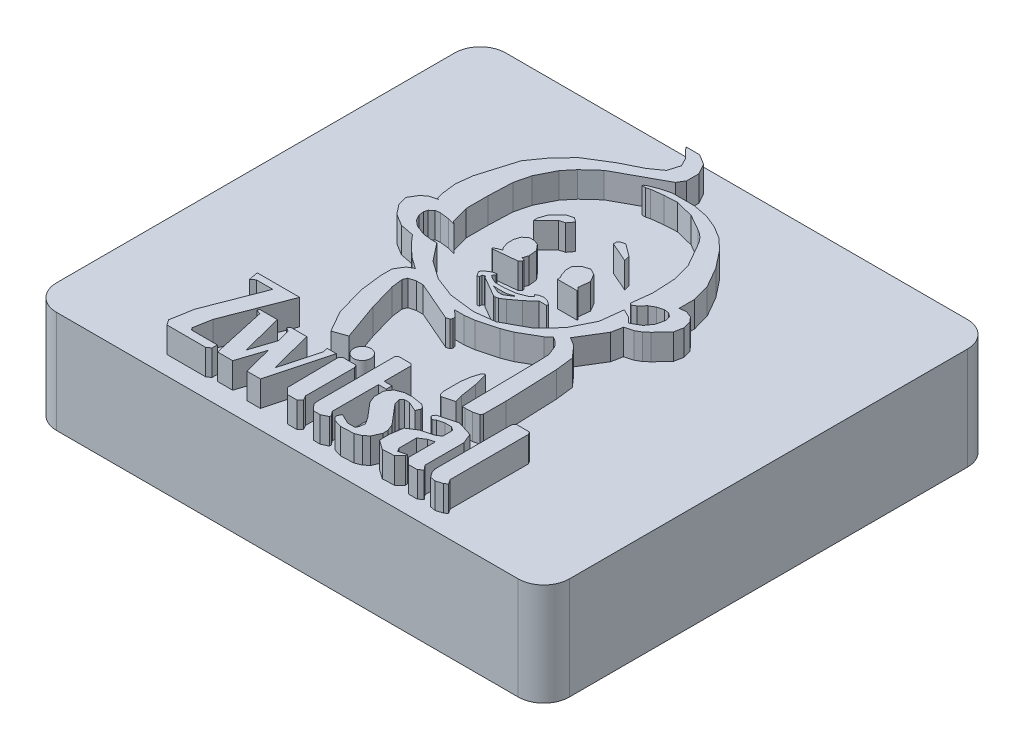
from build123d import *

# Parameters (mm, degrees)
SKETCH1_W           = 200.42742068
SKETCH1_H           = 175.574420516
BOSS_EXTRUDE1_DEPTH = 40
FILLET1_R           = 10
FILLET2_R           = 10
FILLET3_R           = 10
FILLET4_R           = 10
SKETCH2_R           = 3.383541927
BOSS_EXTRUDE2_DEPTH = 10


with BuildPart() as part:
    # Sketch1 → Boss-Extrude1 (new body)
    with BuildSketch(Plane(origin=(0, 0, 0), x_dir=(1, 0, 0), z_dir=(0, 1, 0))):
        Rectangle(SKETCH1_W, SKETCH1_H)
    extrude(amount=BOSS_EXTRUDE1_DEPTH)

    # Fillet1
    fillet1_edges = [part.edges().sort_by_distance(p)[0] for p in [
        (-100.21371034, 20, -87.787210258),
    ]]
    fillet(fillet1_edges, radius=FILLET1_R)

    # Fillet2
    fillet2_edges = [part.edges().sort_by_distance(p)[0] for p in [
        (100.21371034, 20, -87.787210258),
    ]]
    fillet(fillet2_edges, radius=FILLET2_R)

    # Fillet3
    fillet3_edges = [part.edges().sort_by_distance(p)[0] for p in [
        (100.21371034, 20, 87.787210258),
    ]]
    fillet(fillet3_edges, radius=FILLET3_R)

    # Fillet4
    fillet4_edges = [part.edges().sort_by_distance(p)[0] for p in [
        (-100.21371034, 20, 87.787210258),
    ]]
    fillet(fillet4_edges, radius=FILLET4_R)

    # Sketch2 → Boss-Extrude2 (add)
    with BuildSketch(Plane(origin=(0, 40, 0), x_dir=(1, 0, 0), z_dir=(0, 1, 0))):
        with Locations(Location((-6.562454807, -51.982973515, 0), (0, 0, 90))):  # turned: the seam where the file's is
            Circle(SKETCH2_R)
        Polygon((-54.350495616, -45.195328484), (-37.774987445, -45.195328484), (-47.275583592, -69.654310053), (-48.488425653, -76.527081734), (-47.882004623, -77.393397492), (-40.706022427, -77.393397492), (-37.774987445, -77.393397492), (-37.774987445, -79.458116716), (-39.240504936, -80.483978959), (-54.350495616, -80.483978959), (-55.791250915, -78.425757104), (-54.243348494, -69.654310054), (-45.736459991, -47.753597099), (-52.126951837, -47.753597099), (-53.66550681, -48.83058558), align=None)
        Polygon((-41.536724423, -57.106367988), (-34.588424162, -57.106367988), (-30.391925985, -73.548385438), (-27.244252146, -63.988459146), (-28.535577857, -58.929002674), (-29.999459948, -58.060432633), (-29.433381592, -57.106367988), (-23.099650463, -57.106367988), (-18.779344484, -74.033468461), (-14.706654108, -58.929002674), (-15.050092368, -57.583400311), (-15.050092368, -57.106367988), (-11.542081712, -57.106367988), (-17.845500354, -80.483978959), (-23.099650463, -80.483978959), (-25.972947124, -69.226308436), (-29.433381592, -79.736132564), (-35.345169735, -79.736132564), (-40.028023669, -58.494717653), (-41.803095041, -57.910262758), align=None)
        Polygon((-9.061414217, -57.106367988), (-3.850039691, -57.106367988), (-3.280849938, -58.181492373), (-3.280849938, -77.393397492), (-2.289801236, -79.265357803), (-3.565444815, -80.483978959), (-7.346119473, -80.483978959), (-9.644610411, -78.077935712), (-9.874578651, -58.181492373), align=None)
        Polygon((1.596557726, -45.873051228), (6.474066731, -45.873051228), (7.161920565, -46.560905062), (7.161920565, -57.106367988), (10.225996735, -57.106367988), (10.225996735, -59.338311131), (7.161920565, -59.338311131), (7.161920565, -77.393397492), (8.401493812, -79.013015335), (8.401493812, -79.736132564), (5.949955166, -80.889298517), (3.263405141, -80.889298517), (1.029453545, -78.425757104), (0.861907175, -76.276424629), (0.861907175, -46.560905062), align=None)
        Polygon((23.754507268, -59.338311131), (23.019641294, -60.997850668), (20.527004671, -59.894078328), (19.271921882, -59.338311131), (17.366826111, -59.338311131), (16.259172744, -60.445964498), (16.812999428, -62.524110768), (23.387074281, -70.268467569), (24.489373242, -72.981818857), (24.489373242, -74.903776019), (23.61101965, -76.887352026), (23.019641294, -78.222855093), (21.236978192, -79.736132564), (18.946454871, -80.666657663), (13.779443961, -80.889298517), (10.886521682, -79.97001904), (9.603090682, -78.68658804), (9.603090682, -77.890476041), (10.244806182, -76.527081734), (11.693145857, -77.208778888), (14.171479034, -78.375268145), (17.052375995, -78.375268145), (17.601413227, -77.208778888), (17.912749488, -75.162769513), (16.362949416, -72.759148027), (11.501834636, -67.03268337), (10.367999813, -64.241705344), (10.367999813, -60.445964498), (11.980940982, -58.181492373), (14.988277067, -56.959762088), (17.912749488, -56.833749767), (22.128309743, -57.475221298), (23.387074281, -58.37181575), align=None)
        Polygon((28.818926102, -58.37181575), (35.934380342, -56.47554479), (41.901841432, -58.37181575), (43.51547422, -62.343834921), (43.51547422, -77.555103559), (44.981160612, -79.281703671), (43.515474221, -80.525904099), (40.015827521, -80.525904099), (37.657150289, -78.167226868), (37.657150289, -72.981818857), (37.657150289, -67.632409431), (35.267034805, -68.269376016), (32.661338596, -69.94946924), (32.661338596, -76.887352025), (33.486572575, -78.167226868), (35.267034805, -77.692733082), (36.462092547, -77.374249789), (36.462092547, -78.167226868), (34.37680369, -80.252515725), (29.828444424, -80.525904099), (26.128462371, -77.890476041), (26.128462371, -73.942797438), (26.863945237, -69.109422628), (30.576321686, -66.715767337), (35.267034805, -65.465690705), (37.165342571, -64.241705344), (37.165342571, -60.357825335), (35.734006114, -59.338311131), (33.073955585, -59.338311131), (30.576321686, -60.003931409), (29.447802643, -60.731574636), (27.978453397, -59.684984633), align=None)
        Polygon((47.621556798, -45.873051228), (52.745311121, -45.873051228), (53.30334377, -46.920870207), (53.30334377, -77.555103559), (54.515212089, -79.281703671), (53.30334377, -80.132291373), (50.830505637, -80.889298517), (48.701564132, -80.510794945), (47.2329538, -78.418403615), (46.764254706, -76.887352025), (46.764254706, -46.920870207), align=None)
        with BuildLine():
            Line((-13.143205909, 81.22212833), (-7.914354756, 81.22212833))
            Line((-7.914354756, 81.22212833), (-3.849225184, 78.724766585))
            Line((-3.849225184, 78.724766585), (-1.59290784, 74.588511196))
            Line((-1.59290784, 74.588511196), (-1.59290784, 69.82791537))
            Line((-1.59290784, 69.82791537), (-3.280035431, 67.081660336))
            Line((-3.280035431, 67.081660336), (-8.442043104, 64.265797595))
            Line((-8.442043104, 64.265797595), (-21.269632172, 57.268378682))
            Line((-21.269632172, 57.268378682), (-26.667470445, 52.328282066))
            Line((-26.667470445, 52.328282066), (-29.99864544, 48.348091756))
            Line((-29.99864544, 48.348091756), (-33.490653834, 41.393693303))
            Line((-33.490653834, 41.393693303), (-34.986422246, 35.439432412))
            Line((-34.986422246, 35.439432412), (-35.344355228, 25.916651978))
            Line((-35.344355228, 25.916651978), (-35.344355228, 17.416734811))
            Line((-35.344355228, 17.416734811), (-33.490653834, 10.616801077))
            Line((-33.490653834, 10.616801077), (-32.48080471, 9.771619342))
            Line((-32.48080471, 9.771619342), (-35.344355228, 10.490971163))
            Line((-35.344355228, 10.490971163), (-38.908290485, 10.92086002))
            Line((-38.908290485, 10.92086002), (-40.70520792, 10.705915592))
            Line((-40.70520792, 10.705915592), (-42.164965716, 9.369946601))
            Line((-42.164965716, 9.369946601), (-42.525085047, 7.936406202))
            Line((-42.525085047, 7.936406202), (-42.283377838, 5.915754162))
            Line((-42.283377838, 5.915754162), (-41.119367401, 3.781903417))
            Line((-41.119367401, 3.781903417), (-38.908290485, 1.931367749))
            Line((-38.908290485, 1.931367749), (-34.986422246, 0.429123691))
            Line((-34.986422246, 0.429123691), (-31.744649637, 0.038094724))
            Line((-31.744649637, 0.038094724), (-29.432567085, 0.038094724))
            Line((-29.432567085, 0.038094724), (-23.968551309, -6.898706808))
            Line((-23.968551309, -6.898706808), (-17.031612096, -11.815600825))
            Line((-17.031612096, -11.815600825), (-9.060599709, -14.868841084))
            Line((-9.060599709, -14.868841084), (-5.022079929, -15.355975257))
            Line((-5.022079929, -15.355975257), (0.862721683, -16.065811563))
            Line((0.862721683, -16.065811563), (8.833094259, -15.112408171))
            Line((8.833094259, -15.112408171), (18.484785879, -9.84743366))
            Line((18.484785879, -9.84743366), (24.490187749, -3.430306042))
            Line((24.490187749, -3.430306042), (28.81974061, 5.192077505))
            Line((28.81974061, 5.192077505), (29.678235561, 12.309313446))
            Line((29.678235561, 12.309313446), (29.884192069, 14.016767944))
            Line((29.884192069, 14.016767944), (31.108472469, 13.402020679))
            Line((31.108472469, 13.402020679), (33.074770093, 12.414684699))
            Line((33.074770093, 12.414684699), (34.671010247, 10.92086002))
            Line((34.671010247, 10.92086002), (35.267849312, 10.362314413))
            Line((35.267849312, 10.362314413), (38.853767192, 12.414684699))
            Line((38.853767192, 12.414684699), (40.756526134, 15.099168658))
            Line((40.756526134, 15.099168658), (41.620041994, 18.536598323))
            Line((41.620041994, 18.536598323), (41.072544852, 20.544982358))
            Line((41.072544852, 20.544982358), (39.489992687, 21.666693394))
            Line((39.489992687, 21.666693394), (37.657964796, 21.88767619))
            Line((37.657964796, 21.88767619), (35.267849312, 21.23611684))
            Line((35.267849312, 21.23611684), (33.074770093, 19.980926181))
            Line((33.074770093, 19.980926181), (31.019612286, 17.784868331))
            Line((31.019612286, 17.784868331), (29.547813512, 16.942496539))
            Line((29.547813512, 16.942496539), (28.81974061, 17.45855372))
            Line((28.81974061, 17.45855372), (29.754996751, 25.212167899))
            Line((29.754996751, 25.212167899), (29.28736868, 34.551399597))
            Line((29.28736868, 34.551399597), (27.422119712, 41.393693303))
            Line((27.422119712, 41.393693303), (22.12912425, 50.641657567))
            ThreePointArc((22.12912425, 50.641657567), (20.067070689, 53.336079618), (17.367640618, 55.391572837))
            Line((17.367640618, 55.391572837), (11.057474267, 58.982794586))
            Line((11.057474267, 58.982794586), (3.952825362, 60.767551688))
            Line((3.952825362, 60.767551688), (-1.031039661, 60.518002768))
            Line((-1.031039661, 60.518002768), (-5.861853775, 59.940148405))
            Line((-5.861853775, 59.940148405), (-7.346119473, 59.535528963))
            Line((-7.346119473, 59.535528963), (-8.673497652, 59.535528963))
            Line((-8.673497652, 59.535528963), (-8.571853301, 59.940148405))
            Line((-8.571853301, 59.940148405), (-7.346119473, 60.641686972))
            Line((-7.346119473, 60.641686972), (-4.407567641, 61.779546045))
            Line((-4.407567641, 61.779546045), (-0.269475754, 62.907613905))
            Line((-0.269475754, 62.907613905), (3.845669527, 62.907613905))
            Line((3.845669527, 62.907613905), (8.401493812, 62.907613905))
            Line((8.401493812, 62.907613905), (14.212150189, 61.779546045))
            Line((14.212150189, 61.779546045), (19.271921882, 59.737838684))
            Line((19.271921882, 59.737838684), (24.047041286, 56.804303526))
            Line((24.047041286, 56.804303526), (28.232006759, 52.887847289))
            Line((28.232006759, 52.887847289), (33.68071258, 45.9704824))
            Line((33.68071258, 45.9704824), (38.257999419, 37.97301))
            Line((38.257999419, 37.97301), (40.083232826, 31.277505399))
            Line((40.083232826, 31.277505399), (40.083232826, 25.212631449))
            Line((40.083232826, 25.212631449), (42.725419342, 25.528685631))
            Line((42.725419342, 25.528685631), (45.201670945, 24.529474316))
            Line((45.201670945, 24.529474316), (46.764254706, 22.735650031))
            Line((46.764254706, 22.735650031), (47.621556798, 19.590808349))
            Line((47.621556798, 19.590808349), (46.953074624, 16.147469221))
            Line((46.953074624, 16.147469221), (44.715910349, 13.756926679))
            Line((44.715910349, 13.756926679), (42.725419342, 11.629969134))
            Line((42.725419342, 11.629969134), (40.890098595, 10.031238189))
            Line((40.890098595, 10.031238189), (38.853767192, 8.86576084))
            Line((38.853767192, 8.86576084), (35.614899624, 7.982826747))
            Line((35.614899624, 7.982826747), (34.799341745, 3.781903417))
            Line((34.799341745, 3.781903417), (32.475976463, 0))
            Line((32.475976463, 0), (29.948337699, -4.114413585))
            Line((29.948337699, -4.114413585), (28.81974061, -5.951509637))
            Line((28.81974061, -5.951509637), (32.091621281, -7.961548794))
            Line((32.091621281, -7.961548794), (36.027533488, -12.479920915))
            Line((36.027533488, -12.479920915), (36.859921361, -19.438613876))
            Line((36.859921361, -19.438613876), (37.657150289, -39.925336181))
            Line((37.657150289, -39.925336181), (37.657150289, -48.83058558))
            Line((37.657150289, -48.83058558), (37.165342571, -49.631135241))
            Line((37.165342571, -49.631135241), (34.799341744, -50.276120795))
            Line((34.799341744, -50.276120795), (32.091621281, -50.381490168))
            Line((32.091621281, -50.381490168), (30.956359669, -50.381490168))
            Line((30.956359669, -50.381490168), (30.904163941, -49.040194896))
            Line((30.904163941, -49.040194896), (30.455680945, -20.20467901))
            Line((30.455680945, -20.20467901), (30.290473212, -15.959267396))
            Line((30.290473212, -15.959267396), (28.81974061, -12.16106067))
            Line((28.81974061, -12.16106067), (27.129540719, -10.220734855))
            Line((27.129540719, -10.220734855), (25.31414771, -9.10547076))
            Line((25.31414771, -9.10547076), (23.387074281, -10.784126619))
            Line((23.387074281, -10.784126619), (20.040566275, -12.699472655))
            Line((20.040566275, -12.699472655), (15.824665924, -15.112408171))
            Line((15.824665924, -15.112408171), (11.980940981, -16.600766229))
            Line((11.980940981, -16.600766229), (7.865193618, -17.722742843))
            Line((7.865193618, -17.722742843), (4.285445933, -18.698602834))
            Line((4.285445933, -18.698602834), (0.490391889, -19.152561212))
            Line((0.490391889, -19.152561212), (-3.280849939, -19.152561212))
            Line((-3.280849939, -19.152561212), (-2.079679123, -20.276664376))
            Line((-2.079679123, -20.276664376), (-0.854642502, -21.423102105))
            Line((-0.854642502, -21.423102105), (-0.587725844, -22.402232614))
            Line((-0.587725844, -22.402232614), (-1.095354508, -23.228535131))
            Line((-1.095354508, -23.228535131), (-2.357949379, -23.57272582))
            Line((-2.357949379, -23.57272582), (-14.706654108, -18.210672839))
            Line((-14.706654108, -18.210672839), (-17.845500354, -16.847723425))
            Line((-17.845500354, -16.847723425), (-20.500081702, -16.847723425))
            Line((-20.500081702, -16.847723425), (-23.099650463, -17.556380954))
            Line((-23.099650463, -17.556380954), (-23.792743649, -19.152561212))
            Line((-23.792743649, -19.152561212), (-23.264010533, -23.57272582))
            Line((-23.264010533, -23.57272582), (-20.249876066, -34.06225182))
            Line((-20.249876066, -34.06225182), (-15.050092368, -48.669345176))
            Line((-15.050092368, -48.669345176), (-20.249876066, -50.520346593))
            Line((-20.249876066, -50.520346593), (-24.950326961, -42.307680964))
            Line((-24.950326961, -42.307680964), (-28.287478609, -30.694018947))
            Line((-28.287478609, -30.694018947), (-29.337890031, -21.91266736))
            Line((-29.337890031, -21.91266736), (-29.337890031, -17.556380954))
            Line((-29.337890031, -17.556380954), (-27.244252146, -14.148420814))
            Line((-27.244252146, -14.148420814), (-24.950326961, -12.835511806))
            Line((-24.950326961, -12.835511806), (-29.337890031, -9.725612477))
            Line((-29.337890031, -9.725612477), (-33.912579969, -5.444436669))
            Line((-33.912579969, -5.444436669), (-36.947356366, -1.960555845))
            Line((-36.947356366, -1.960555845), (-42.283377838, -0.924632545))
            Line((-42.283377838, -0.924632545), (-46.932288345, 1.931367749))
            Line((-46.932288345, 1.931367749), (-49.841690729, 5.624978409))
            Line((-49.841690729, 5.624978409), (-50.86259079, 9.369946601))
            Line((-50.86259079, 9.369946601), (-48.807928928, 12.714462753))
            Line((-48.807928928, 12.714462753), (-46.932288345, 14.191877047))
            Line((-46.932288345, 14.191877047), (-43.604070082, 15.099168658))
            Line((-43.604070082, 15.099168658), (-44.373770166, 15.248596515))
            Line((-44.373770166, 15.248596515), (-45.06517258, 17.784868331))
            Line((-45.06517258, 17.784868331), (-45.764664492, 23.632562174))
            Line((-45.764664492, 23.632562174), (-45.010871135, 29.881783748))
            Line((-45.010871135, 29.881783748), (-40.70520792, 44.305356922))
            Line((-40.70520792, 44.305356922), (-36.429145413, 50.338186911))
            Line((-36.429145413, 50.338186911), (-30.588608361, 56.579146705))
            Line((-30.588608361, 56.579146705), (-21.269632172, 62.343579975))
            Line((-21.269632172, 62.343579975), (-13.722580142, 66.099630933))
            Line((-13.722580142, 66.099630933), (-9.060599709, 69.432752884))
            Line((-9.060599709, 69.432752884), (-7.717826666, 73.930918272))
            Line((-7.717826666, 73.930918272), (-9.363570868, 77.237720352))
            Line((-9.363570868, 77.237720352), (-11.803104054, 79.52073201))
            Line((-11.803104054, 79.52073201), (-13.143205909, 81.22212833))
        make_face()
        Polygon((23.387074281, -51.188758433), (27.978453397, -49.931927357), (27.129540719, -46.830731011), (26.128462371, -40.409014974), (24.928526391, -36.025481574), (24.666510987, -35.06830278), (24.221011296, -35.06830278), (23.61101965, -35.678294427), (22.667250415, -38.559649343), (22.128309743, -42.307680964), (22.128309743, -46.560905062), (22.128309743, -49.040194896), (22.544430738, -50.560342895), align=None)
        Polygon((-11.018972966, 35.439432411), (-13.722580142, 34.699354663), (-17.031612096, 31.39032271), (-18.122138229, 28.060914716), (-18.122138229, 26.430223459), (-15.377096119, 29.175265569), (-13.143205909, 31.409155779), (-11.018972966, 31.99063727), (-9.363570868, 34.210368969), align=None)
        Polygon((5.432141679, 34.210368969), (13.235041906, 30.786842753), (12.60170709, 33.100503119), (10.225996735, 34.864363846), (7.865193618, 36.617156603), (5.949955166, 36.09288467), (5.432141679, 35.395451565), align=None)
        Polygon((-16.418121827, 8.86576084), (-7.346119473, 9.771619342), (-6.562454807, 10.72914558), (-6.617558286, 11.280996551), (-7.717826666, 11.629969134), (-7.04321865, 13.756926679), (-7.361304496, 16.942496539), (-9.363570868, 19.2823928), (-11.284393825, 19.891621022), (-13.143205909, 19.891621022), (-14.861013599, 18.421680398), (-15.582326111, 16.147469221), (-15.582326111, 13.756926679), (-14.861013599, 11.455482843), (-14.002109754, 10.451747314), (-15.89225946, 9.859341533), (-16.826406689, 9.059984906), align=None)
        Polygon((6.474066731, 11.280996551), (14.212150189, 11.280996551), (14.212150189, 11.629969134), (13.235041906, 12.607077417), (13.723596047, 16.942496539), (11.980940982, 19.980926181), (9.603090682, 21.23611684), (6.900200441, 20.400886568), (4.961025233, 18.46171136), (4.961025233, 16.147469221), (5.699735768, 13.756926679), (6.474066731, 12.40683153), align=None)
        Polygon((-7.717826666, -0.266511893), (-7.04321865, 0.719712692), (-7.159492104, 1.339418963), (-8.673497652, 1.029565827), (-10.294802677, 0), (-11.284393825, -0.924632545), (-11.542081712, -1.523482127), (-10.532867938, -3.11273783), (-9.644610411, -3.11273783), (-9.644610411, -2.073993293), (-9.060599709, -1.703133121), (-8.442043104, -1.841210081), (-8.442043104, -2.14770988), (-0.587725844, -6.676882213), (0.278635293, -6.870275204), (1.372613292, -6.646384008), (3.263405141, -5.445687875), (6.900200441, -2.785947908), (9.603090682, -0.260480407), (10.225996735, 0.321536935), (13.235041906, 0.321536935), (13.235041906, 1.029565827), (11.501834636, 2.215133024), (9.914543709, 2.569455175), (8.401493812, 2.259797621), (7.161920565, 1.622349426), (7.781707189, 0.95902067), (7.718429912, 0.675551381), (6.438546897, -0.260480407), (3.07755253, -1.523214157), (-1.095354508, -1.994459981), (-4.514884474, -1.994459981), (-6.617558286, -1.089669216), align=None)
        with BuildLine():
            Line((-3.850039691, -3.430306042), (-0.854642502, -4.720457619))
            Line((-0.854642502, -4.720457619), (0.862721683, -4.720457619))
            Line((0.862721683, -4.720457619), (4.064828131, -2.785947908))
            ThreePointArc((4.064828131, -2.785947908), (3.867551031, -2.81591609), (3.706864351, -2.697610819))
            Line((3.706864351, -2.697610819), (1.596557726, -3.430306042))
            Line((1.596557726, -3.430306042), (-0.269475754, -3.580457326))
            Line((-0.269475754, -3.580457326), (-2.079679123, -3.580457326))
            Line((-2.079679123, -3.580457326), (-3.850039691, -3.430306042))
        make_face(mode=Mode.SUBTRACT)
    extrude(amount=BOSS_EXTRUDE2_DEPTH)


solid = part.part
